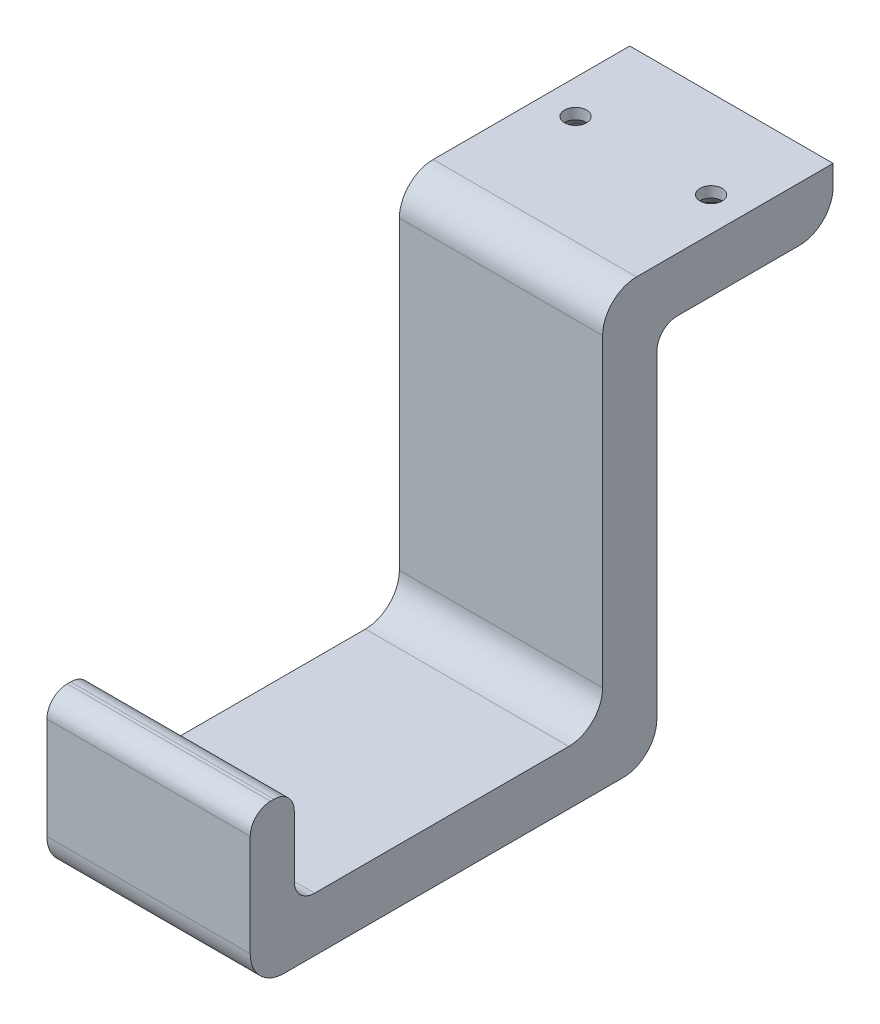
from build123d import *

# Parameters (mm, degrees)
BOSS_EXTRUDE1_DEPTH                           = 15
FILLET1_R                                     = 5
FILLET2_R                                     = 3
CSK_FOR_4_FLAT_HEAD_MACHINE_SCREW2_AT_2_COUNT = 2
CSK_FOR_4_FLAT_HEAD_MACHINE_SCREW2_AT_2_PITCH = 20


with BuildPart() as part:
    # Sketch1 → Boss-Extrude1 (new body, symmetric)
    with BuildSketch(Plane(origin=(0, 0, 0), x_dir=(0, 0, -1), z_dir=(1, 0, 0))):
        Polygon((-60, 0), (0, 0), (0, 55), (26, 55), (26, 63), (-8, 63), (-8, 8), (-53.5, 8), (-53.5, 23), (-60, 23), align=None)
    extrude(amount=BOSS_EXTRUDE1_DEPTH, both=True)

    # Fillet1
    fillet1_edges = [part.edges().sort_by_distance(p)[0] for p in [
        (0, 8, 8),
        (0, 63, 8),
        (0, 55, -26),
        (0, 0, 0),
        (0, 0, 60),
    ]]
    fillet(fillet1_edges, radius=FILLET1_R)

    # Fillet2
    fillet2_edges = [part.edges().sort_by_distance(p)[0] for p in [
        (0, 23, 60),
        (0, 23, 53.5),
        (0, 8, 53.5),
        (0, 55, 0),
    ]]
    fillet(fillet2_edges, radius=FILLET2_R)

    # Sketch6 → CSK for #4 Flat Head Machine Screw2 (revolve, cut)
    with BuildSketch(Plane(origin=(-10, 55, -13), x_dir=(0, 0, -1), z_dir=(1, 0, 0))):
        Polygon((0, 0), (0, 8), (1.63195, 8), (1.63195, 6.409835609), (2.857501397, 5), (2.857501397, 0), align=None)
    csk_for_4_flat_head_machine_screw2 = revolve(axis=Axis((-10, 48.65, -13), (0, 1, 0)), mode=Mode.SUBTRACT)

    # CSK for #4 Flat Head Machine Screw2 at 2: CSK for #4 Flat Head Machine Screw2 ×2
    with Locations(*[(i * CSK_FOR_4_FLAT_HEAD_MACHINE_SCREW2_AT_2_PITCH, 0, 0) for i in range(1, CSK_FOR_4_FLAT_HEAD_MACHINE_SCREW2_AT_2_COUNT)]):
        add(csk_for_4_flat_head_machine_screw2, mode=Mode.SUBTRACT)


solid = part.part
